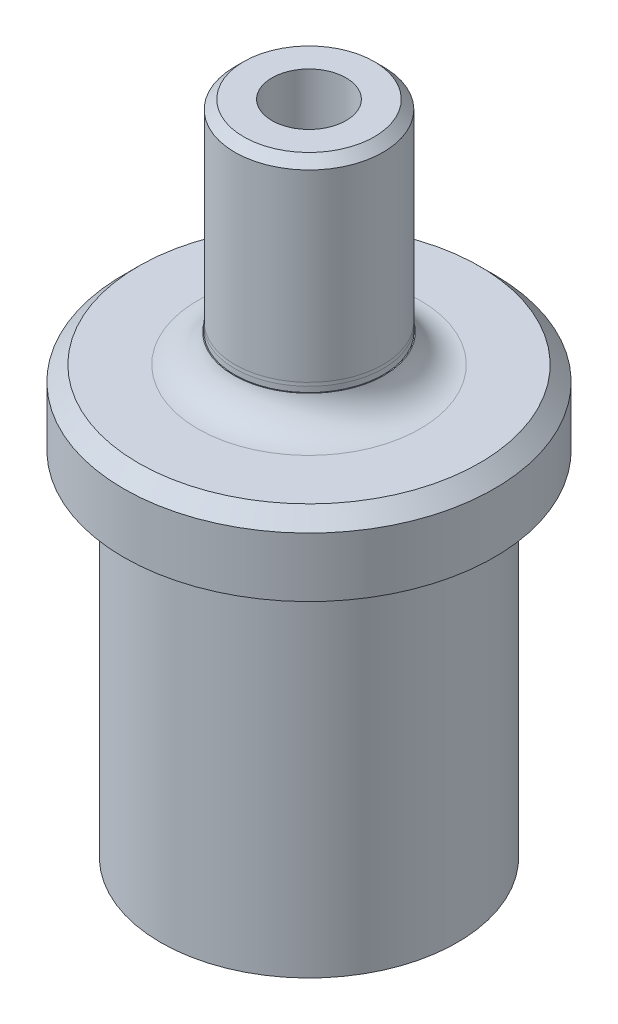
from build123d import *

# Parameters (mm, degrees)
SKETCH1_R                       = 12.7
BOSS_EXTRUDE1_DEPTH             = 30.1625
SKETCH4_R                       = 15.875
BOSS_EXTRUDE2_DEPTH             = 50.8
CUT_EXTRUDE1_DEPTH              = 11.176
SKETCH3_R                       = 6
CUT_EXTRUDE2_DEPTH              = 8
SKETCH5_R                       = 3.175
BOSS_EXTRUDE3_DEPTH             = 6.604
F_8_32_TAPPED_HOLE1_D           = 3.4544
CUT_EXTRUDE3_START              = -6.35
SKETCH9_R                       = 15.875
SKETCH9_R_2                     = 6.35
CUT_EXTRUDE3_DEPTH              = 38.1
FILLET1_R                       = 3.175
CHAMFER1_SIZE                   = 1.27
F_1_4_0_25_DIAMETER_HOLE1_D     = 6.35
F_1_4_0_25_DIAMETER_HOLE1_DEPTH = 6.35
F_1_4_0_25_DIAMETER_HOLE1_TIP   = 1.907732465
CHAMFER2_SIZE                   = 0.762


with BuildPart() as part:
    # Sketch1 → Boss-Extrude1 (new body)
    with BuildSketch(Plane(origin=(0, 0, 0), x_dir=(1, 0, 0), z_dir=(0, 1, 0))):
        Circle(SKETCH1_R)
    extrude(amount=BOSS_EXTRUDE1_DEPTH)

    # Sketch4 → Boss-Extrude2 (add)
    with BuildSketch(Plane(origin=(0, 30.1625, 0), x_dir=(1, 0, 0), z_dir=(0, 1, 0))):
        Circle(SKETCH4_R)
    extrude(amount=BOSS_EXTRUDE2_DEPTH)

    # Sketch2 → Cut-Extrude1 (cut)
    with BuildSketch(Plane.XZ):
        with BuildLine():
            Line((-7, 2.899494937), (-8.776962921, 1.122532015))
            ThreePointArc((-8.776962921, 1.122532015), (-9.241930906, 0), (-8.776962921, -1.122532015))
            Line((-8.776962921, -1.122532015), (-7, -2.899494937))
            Line((-7, -2.899494937), (-7, 2.899494937))
        make_face()
        Polygon((-2.899494937, 7), (-7, 2.899494937), (-7, -2.899494937), (-2.899494937, -7), (2.899494937, -7), (7, -2.899494937), (7, 2.899494937), (2.899494937, 7), align=None)
        with BuildLine():
            Line((-7, 5.4125), (-7, 2.899494937))
            Line((-7, 2.899494937), (-2.899494937, 7))
            Line((-2.899494937, 7), (-5.4125, 7))
            ThreePointArc((-5.4125, 7), (-6.535032015, 6.535032015), (-7, 5.4125))
        make_face()
        with BuildLine():
            Line((-1.122532015, 8.776962921), (-2.899494937, 7))
            Line((-2.899494937, 7), (2.899494937, 7))
            Line((2.899494937, 7), (1.122532015, 8.776962921))
            ThreePointArc((1.122532015, 8.776962921), (0, 9.241930906), (-1.122532015, 8.776962921))
        make_face()
        with BuildLine():
            Line((5.4125, 7), (2.899494937, 7))
            Line((2.899494937, 7), (7, 2.899494937))
            Line((7, 2.899494937), (7, 5.4125))
            ThreePointArc((7, 5.4125), (6.535032015, 6.535032015), (5.4125, 7))
        make_face()
        with BuildLine():
            Line((8.776962921, 1.122532015), (7, 2.899494937))
            Line((7, 2.899494937), (7, -2.899494937))
            Line((7, -2.899494937), (8.776962921, -1.122532015))
            ThreePointArc((8.776962921, -1.122532015), (9.241930906, 0), (8.776962921, 1.122532015))
        make_face()
        with BuildLine():
            Line((7, -2.899494937), (2.899494937, -7))
            Line((2.899494937, -7), (5.4125, -7))
            ThreePointArc((5.4125, -7), (6.535032015, -6.535032015), (7, -5.4125))
            Line((7, -5.4125), (7, -2.899494937))
        make_face()
        with BuildLine():
            Line((2.899494937, -7), (-2.899494937, -7))
            Line((-2.899494937, -7), (-1.122532015, -8.776962921))
            ThreePointArc((-1.122532015, -8.776962921), (0, -9.241930906), (1.122532015, -8.776962921))
            Line((1.122532015, -8.776962921), (2.899494937, -7))
        make_face()
        with BuildLine():
            Line((-2.899494937, -7), (-7, -2.899494937))
            Line((-7, -2.899494937), (-7, -5.4125))
            ThreePointArc((-7, -5.4125), (-6.535032015, -6.535032015), (-5.4125, -7))
            Line((-5.4125, -7), (-2.899494937, -7))
        make_face()
    extrude(amount=-CUT_EXTRUDE1_DEPTH, mode=Mode.SUBTRACT)

    # Sketch3 → Cut-Extrude2 (cut)
    with BuildSketch(Plane.XZ.offset(-11.176)):
        Circle(SKETCH3_R)
    extrude(amount=-CUT_EXTRUDE2_DEPTH, mode=Mode.SUBTRACT)

    # Sketch5 → Boss-Extrude3 (add)
    with BuildSketch(Plane(origin=(0, 80.9625, 0), x_dir=(1, 0, 0), z_dir=(0, 1, 0))):
        Circle(SKETCH5_R)
    extrude(amount=BOSS_EXTRUDE3_DEPTH)

    # #8-32 Tapped Hole1 (through all)
    with Locations(Plane(origin=(0, 87.5665, 0), x_dir=(1, 0, 0), z_dir=(0, 1, 0))):
        with Locations((0, 0)):
            Hole(F_8_32_TAPPED_HOLE1_D / 2)

    # Sketch9 → Cut-Extrude3 (cut)
    with BuildSketch(Plane(origin=(0, 80.9625, 0), x_dir=(1, 0, 0), z_dir=(0, 1, 0)).offset(CUT_EXTRUDE3_START)):
        Circle(SKETCH9_R)
        Circle(SKETCH9_R_2, mode=Mode.SUBTRACT)
    extrude(amount=-CUT_EXTRUDE3_DEPTH, mode=Mode.SUBTRACT)

    # Fillet1
    fillet1_edges = [part.edges().sort_by_distance(p)[0] for p in [
        (-6.35, 36.5125, 0),
        (-6.35, 74.6125, 0),
    ]]
    fillet(fillet1_edges, radius=FILLET1_R)

    # Chamfer1
    chamfer1_edges = [part.edges().sort_by_distance(p)[0] for p in [
        (-15.875, 36.5125, 0),
    ]]
    chamfer(chamfer1_edges, length=CHAMFER1_SIZE)

    # Sketch10 → Cut-Revolve1 (revolve, cut)
    with BuildSketch(Plane.XY):
        Polygon((0, 87.5665), (0, 56.1975), (-6.3627, 56.1975), (-6.3627, 38.9382), (-15.875, 38.9382), (-15.875, 87.5665), align=None)
    revolve(axis=Axis((0, 87.5665, 0), (0, -1, 0)), mode=Mode.SUBTRACT)

    # 1/4 (0.25) Diameter Hole1
    with Locations(Plane(origin=(0, 56.1975, 0), x_dir=(1, 0, 0), z_dir=(0, 1, 0))):
        with Locations((0, 0)):
            Hole(F_1_4_0_25_DIAMETER_HOLE1_D / 2, depth=F_1_4_0_25_DIAMETER_HOLE1_DEPTH)
            with Locations((0, 0, -(F_1_4_0_25_DIAMETER_HOLE1_DEPTH + F_1_4_0_25_DIAMETER_HOLE1_TIP / 2))):  # 118° drill point
                Cone(0, F_1_4_0_25_DIAMETER_HOLE1_D / 2, F_1_4_0_25_DIAMETER_HOLE1_TIP, mode=Mode.SUBTRACT)

    # Chamfer2
    chamfer2_edges = [part.edges().sort_by_distance(p)[0] for p in [
        (-6.35, 56.1975, 0),
    ]]
    chamfer(chamfer2_edges, length=CHAMFER2_SIZE)


solid = part.part
